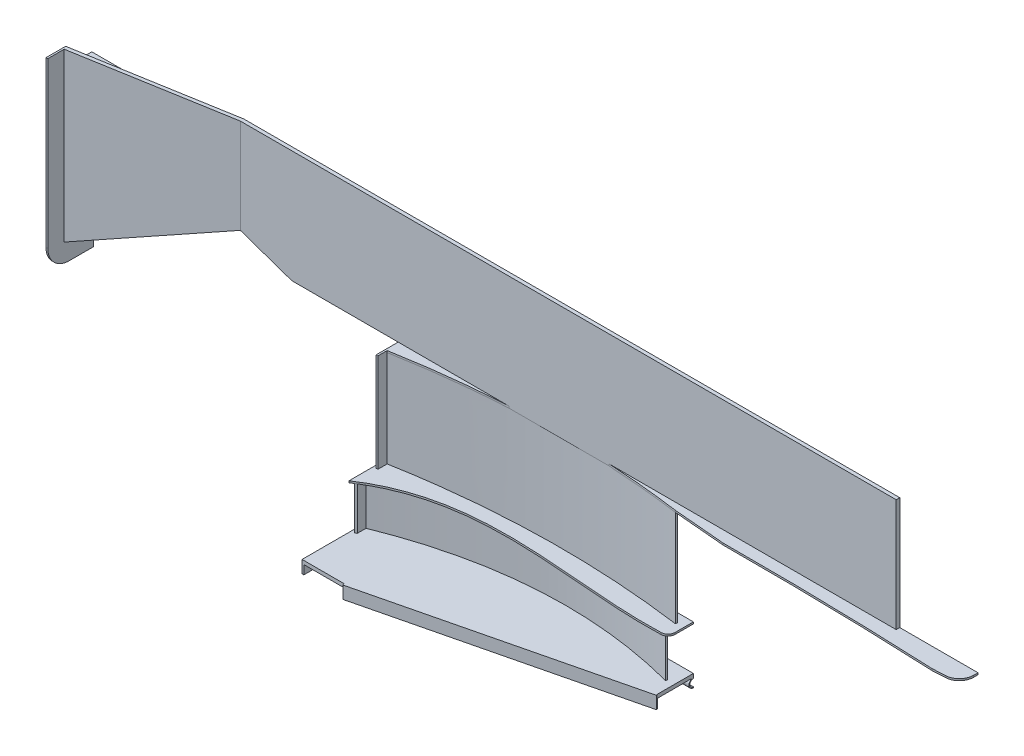
from build123d import *

# Parameters (mm, degrees)
SZKIC1_W                     = 1841.580423823
SZKIC1_H                     = 10
DODANIE_WYCI_GNI_CIE1_DEPTH  = 315
DODANIE_WYCI_GNI_CIE2_DEPTH  = 5
DODANIE_WYCI_GNI_CIE4_DEPTH  = 270
DODANIE_WYCI_GNI_CIE5_DEPTH  = 5
DODANIE_WYCI_GNI_CIE6_DEPTH  = 120
DODANIE_WYCI_GNI_CIE7_DEPTH  = 10
DODANIE_WYCI_GNI_CIE8_DEPTH  = 824.158490967
WYTNIJ_WYCI_GNI_CIE3_DEPTH   = 800
WYTNIJ_WYCI_GNI_CIE4_DEPTH   = 800
WYTNIJ_WYCI_GNI_CIE6_DEPTH   = 800
WYTNIJ_WYCI_GNI_CIE7_DEPTH   = 800
DODANIE_WYCI_GNI_CIE15_REACH = 1830.605
WYTNIJ_WYCI_GNI_CIE8_DEPTH   = 40
SZKIC26_W                    = 726.687402781
SZKIC26_H                    = 35
DODANIE_WYCI_GNI_CIE16_DEPTH = 5
SZKIC10_W                    = 300
SZKIC10_H                    = 35
DODANIE_WYCI_GNI_CIE19_DEPTH = 5
WYTNIJ_WYCI_GNI_CIE10_DEPTH  = 10
WYTNIJ_WYCI_GNI_CIE11_DEPTH  = 35
WYTNIJ_WYCI_GNI_CIE13_DEPTH  = 70
SZKIC30_W                    = 16.697561016
SZKIC30_H                    = 21.994192029
WYTNIJ_WYCI_GNI_CIE14_DEPTH  = 70
DODANIE_WYCI_GNI_CIE20_DEPTH = 5
WYTNIJ_WYCI_GNI_CIE15_DEPTH  = 5
ZAOKR_GLENIE2_R              = 20
SZKIC33_W                    = 30
SZKIC33_H                    = 275
DODANIE_WYCI_GNI_CIE21_DEPTH = 5
SZKIC34_W                    = 36.535261538
SZKIC34_H                    = 120
DODANIE_WYCI_GNI_CIE22_DEPTH = 5
WYTNIJ_WYCI_GNI_CIE16_DEPTH  = 1825.139427117
SZKIC36_W                    = 10
SZKIC36_H                    = 315
DODANIE_WYCI_GNI_CIE23_DEPTH = 90
WYTNIJ_WYCI_GNI_CIE17_DEPTH  = 15
DODANIE_WYCI_GNI_CIE24_DEPTH = 470
WYTNIJ_WYCI_GNI_CIE18_DEPTH  = 235
DODANIE_WYCI_GNI_CIE25_REACH = 2202.156
DODANIE_WYCI_GNI_CIE26_REACH = 2202.156
SZKIC42_W                    = 425.858416348
SZKIC42_H                    = 5
WYTNIJ_WYCI_GNI_CIE20_REACH  = 2202.156
DODANIE_WYCI_GNI_CIE28_DEPTH = 5
SZKIC47_W                    = 59.404380421
SZKIC47_H                    = 10
DODANIE_WYCI_GNI_CIE29_DEPTH = 20
DODANIE_WYCI_GNI_CIE30_DEPTH = 5
WYTNIJ_WYCI_GNI_CIE21_DEPTH  = 5
ZAOKR_GLENIE3_R              = 40
WYTNIJ_WYCI_GNI_CIE22_DEPTH  = 10
WYTNIJ_WYCI_GNI_CIE23_DEPTH  = 120


with BuildPart() as part:
    # Szkic1 → Dodanie-wyciągnięcie1 (new body)
    with BuildSketch(Plane(origin=(0, 0, 0), x_dir=(1, 0, 0), z_dir=(0, 1, 0))):
        with Locations((-708.709788088, -60)):
            Rectangle(SZKIC1_W, SZKIC1_H)
    extrude(amount=-DODANIE_WYCI_GNI_CIE1_DEPTH)

    # Szkic2 → Dodanie-wyciągnięcie2 (add)
    with BuildSketch(Plane.XZ.offset(315)):
        with BuildLine():
            Line((-1189.824091864, 55), (82.698967418, 55))
            Line((82.698967418, 55), (82.698967418, 125))
            add(Edge.make_bspline(
                [(82.698967418, 125), (-575.048967354, 24.979688265), (-1189.824091864, 215)],
                knots=[0, 0, 0, 1, 1, 1], degree=2))
            Line((-1189.824091864, 215), (-1189.824091864, 55))
        make_face()
    extrude(amount=DODANIE_WYCI_GNI_CIE2_DEPTH)

    # Szkic4 → Dodanie-wyciągnięcie4 (add)
    with BuildSketch(Plane.XZ.offset(320)):
        with BuildLine():
            Line((-1182.177359348, 101.771243176), (-1182.177359348, 96.771243176))
            add(Edge.make_bspline(
                [(-385.949338397, 79.815775507), (-787.330452668, 25.09256948), (-1182.177359348, 96.771243176)],
                knots=[0, 0, 0, 1, 1, 1], degree=2))
            Line((-385.949338397, 79.815775507), (-385.949338397, 84.815775507))
            add(Edge.make_bspline(
                [(-385.949338397, 84.815775507), (-787.330452668, 30.09256948), (-1182.177359348, 101.771243176)],
                knots=[0, 0, 0, 1, 1, 1], degree=2))
        make_face()
    extrude(amount=DODANIE_WYCI_GNI_CIE4_DEPTH)

    # Szkic5 → Dodanie-wyciągnięcie5 (add)
    with BuildSketch(Plane.XZ.offset(590)):
        with BuildLine():
            Line((-1189.824091794, 195), (-1189.824091794, 55))
            Line((-1189.824091794, 55), (-365.665600827, 55))
            Line((-365.665600827, 55), (-365.665600827, 125))
            add(Edge.make_bspline(
                [(-1189.824091794, 195), (-948.463478374, 33.501978751), (-627.926523689, 141.485843373), (-365.665600827, 125)],
                knots=[0, 0, 0, 0, 1, 1, 1, 1], degree=3))
        make_face()
    extrude(amount=DODANIE_WYCI_GNI_CIE5_DEPTH)

    # Szkic6 → Dodanie-wyciągnięcie6 (add)
    with BuildSketch(Plane.XZ.offset(595)):
        with BuildLine():
            Line((-1180.731710733, 163.464738462), (-1180.731710733, 158.464738462))
            add(Edge.make_bspline(
                [(-386.71144151, 106.429912395), (-791.410470683, 0.146312653), (-1180.731710733, 158.464738462)],
                knots=[0, 0, 0, 1, 1, 1], degree=2))
            Line((-386.71144151, 106.429912395), (-386.71144151, 111.429912395))
            add(Edge.make_bspline(
                [(-386.71144151, 111.429912395), (-791.410470683, 5.146312653), (-1180.731710733, 163.464738462)],
                knots=[0, 0, 0, 1, 1, 1], degree=2))
        make_face()
    extrude(amount=DODANIE_WYCI_GNI_CIE6_DEPTH)

    # Szkic7 → Dodanie-wyciągnięcie7 (add)
    with BuildSketch(Plane.XZ.offset(715)):
        Polygon((-1189.824091794, 55), (-365.665600827, 55), (-365.665600827, 155), (-1189.824091794, 355), align=None)
    extrude(amount=DODANIE_WYCI_GNI_CIE7_DEPTH)

    # Szkic9 → Dodanie-wyciągnięcie8 (add)
    with BuildSketch(Plane.ZY.offset(1189.824091794)):
        with BuildLine():
            Line((55, -725), (55, -727.5))
            ThreePointArc((55, -727.5), (65, -737.5), (55, -747.5))
            Line((55, -747.5), (55, -750))
            ThreePointArc((55, -750), (67.236328912, -740.053870546), (60, -726.043560763))
            Line((60, -726.043560763), (60, -725))
            Line((60, -725), (55, -725))
        make_face()
    extrude(amount=-DODANIE_WYCI_GNI_CIE8_DEPTH)

    # Szkic14 → Wytnij-wyciągnięcie3 (cut)
    with BuildSketch(Plane(origin=(0, -315, 0), x_dir=(-1, 0, 0), z_dir=(0, -1, 0))):
        Polygon((-212.080423823, -60), (-152.676043402, -65), (-157.068738745, -100.12092383), (-228.037209254, -94.147587352), align=None)
    extrude(amount=-WYTNIJ_WYCI_GNI_CIE3_DEPTH, mode=Mode.SUBTRACT)

    # Szkic15 → Wytnij-wyciągnięcie4 (cut)
    with BuildSketch(Plane.XZ.offset(315)):
        Polygon((-1629.5, 60), (-1533.991072744, 65), (-1548.721576055, 115.377348391), (-1654.554576766, 99.51372944), align=None)
    extrude(amount=-WYTNIJ_WYCI_GNI_CIE4_DEPTH, mode=Mode.SUBTRACT)

    # Szkic17 → Wytnij-wyciągnięcie6 (cut)
    with BuildSketch(Plane.XY):
        Polygon((212.080423823, -300), (152.676043402, -315), (126.143267326, -456.893573372), (421.986335713, -502.224366108), align=None)
    extrude(amount=WYTNIJ_WYCI_GNI_CIE6_DEPTH, mode=Mode.SUBTRACT)

    # Szkic18 → Wytnij-wyciągnięcie7 (cut)
    with BuildSketch(Plane.XY):
        Polygon((-1629.5, -300), (-1533.991072744, -315), (-1533.991072744, -431.408469581), (-1704.18755073, -396.775994669), align=None)
    extrude(amount=WYTNIJ_WYCI_GNI_CIE7_DEPTH, mode=Mode.SUBTRACT)

    # Dodanie-wyciągnięcie15: up to this face of the body (flat: up to its plane)
    dodanie_wyci_gni_cie15_end = Plane(part.part.faces().sort_by_distance((179.077990255, -308.333333333, 58.888888889))[0])
    # Szkic24 → Dodanie-wyciągnięcie15 (add, up to the picked face)
    with BuildSketch(Plane(origin=(0, 0, 0), x_dir=(1, 0, 0), z_dir=(0, 1, 0)), mode=Mode.PRIVATE) as dodanie_wyci_gni_cie15_sk1:
        Polygon((212.080423823, -60), (152.676043402, -65), (212.080423823, -65), align=None)
    dodanie_wyci_gni_cie15_tool1 = split(extrude(dodanie_wyci_gni_cie15_sk1.sketch, amount=-DODANIE_WYCI_GNI_CIE15_REACH, mode=Mode.PRIVATE), bisect_by=dodanie_wyci_gni_cie15_end, keep=Keep.BOTH, mode=Mode.PRIVATE)
    add(dodanie_wyci_gni_cie15_tool1.solids().sort_by(Axis((192.278964, 0, 63.333333), (0, -1, 0)))[0])

    # Szkic25 → Wytnij-wyciągnięcie8 (cut, symmetric)
    with BuildSketch(Plane.XZ.offset(725)):
        Polygon((-1071.856786677, 326.372665231), (-1189.824091794, 326.372665231), (-1281.285885853, 396.255102667), (-1102.826584063, 410.27690495), align=None)
    extrude(amount=WYTNIJ_WYCI_GNI_CIE8_DEPTH, both=True, mode=Mode.SUBTRACT)

    # Szkic26 → Dodanie-wyciągnięcie16 (add)
    with BuildSketch(Plane(origin=(15.185934362, 0, 62.578083739), x_dir=(0.9717950017399135, 0, -0.23582721342822507), z_dir=(0.23582721342822507, 0, 0.9717950017399135))):
        with Locations((-755.248922664, -732.5)):
            Rectangle(SZKIC26_W, SZKIC26_H)
    extrude(amount=DODANIE_WYCI_GNI_CIE16_DEPTH)

    # Szkic10 → Dodanie-wyciągnięcie19 (add)
    with BuildSketch(Plane.ZY.offset(1189.824091794)):
        with Locations((205, -732.5)):
            Rectangle(SZKIC10_W, SZKIC10_H)
    extrude(amount=-DODANIE_WYCI_GNI_CIE19_DEPTH)

    # Szkic27 → Wytnij-wyciągnięcie10 (cut)
    with BuildSketch(Plane(origin=(-1184.824091794, 0, 0), x_dir=(0, 0, -1), z_dir=(1, 0, 0))):
        with BuildLine():
            Line((-55, -747.5), (-38.951461032, -762.248984803))
            Line((-38.951461032, -762.248984803), (-37.343567768, -710.656236911))
            Line((-37.343567768, -710.656236911), (-55, -727.5))
            ThreePointArc((-55, -727.5), (-65, -737.5), (-55, -747.5))
        make_face()
    extrude(amount=-WYTNIJ_WYCI_GNI_CIE10_DEPTH, mode=Mode.SUBTRACT)

    # Szkic28 → Wytnij-wyciągnięcie11 (cut, symmetric)
    with BuildSketch(Plane.XZ.offset(725)):
        Polygon((-1184.824091794, 326.372665231), (-1217.650135451, 326.372665231), (-1219.406429923, 378.737546141), (-1162.034143854, 378.737546141), align=None)
    extrude(amount=WYTNIJ_WYCI_GNI_CIE11_DEPTH, both=True, mode=Mode.SUBTRACT)

    # Szkic29 → Wytnij-wyciągnięcie13 (cut)
    with BuildSketch(Plane.XZ.offset(320)):
        with BuildLine():
            Line((-385.949338397, 84.815775507), (-385.949338397, 334.407178537))
            Line((-385.949338397, 334.407178537), (-1182.177359348, 473.468106308))
            Line((-1182.177359348, 473.468106308), (-1313.585801573, 196.645885604))
            Line((-1313.585801573, 196.645885604), (-1213.513918971, 101.771243176))
            Line((-1213.513918971, 101.771243176), (-1182.177359348, 101.771243176))
            add(Edge.make_bspline(
                [(-871.63878498, 65), (-1027.410026315, 73.675500305), (-1182.177359348, 101.771243176)],
                knots=[0, 0, 0, 1, 1, 1], degree=2))
            Line((-871.63878498, 65), (-592.490024907, 65))
            add(Edge.make_bspline(
                [(-385.949338397, 84.815775507), (-489.436864274, 70.706568575), (-592.490024907, 65)],
                knots=[0, 0, 0, 1, 1, 1], degree=2))
        make_face()
    extrude(amount=-WYTNIJ_WYCI_GNI_CIE13_DEPTH, mode=Mode.SUBTRACT)

    # Szkic30 → Wytnij-wyciągnięcie14 (cut)
    with BuildSketch(Plane.XY.offset(101.771243176)):
        with Locations((-1190.526139856, -325.997096015)):
            Rectangle(SZKIC30_W, SZKIC30_H)
    extrude(amount=-WYTNIJ_WYCI_GNI_CIE14_DEPTH, mode=Mode.SUBTRACT)

    # Szkic31 → Dodanie-wyciągnięcie20 (add)
    with BuildSketch(Plane.XZ.offset(320)):
        Polygon((82.698967418, 125), (-385.949338397, 90.579084574), (-211.590498137, 70.301208148), (82.698967418, 100.951939948), align=None)
    extrude(amount=-DODANIE_WYCI_GNI_CIE20_DEPTH)

    # Szkic32 → Wytnij-wyciągnięcie15 (cut)
    with BuildSketch(Plane(origin=(0, -315, 0), x_dir=(1, 0, 0), z_dir=(0, 1, 0))):
        Polygon((-385.949338397, -84.815775507), (82.698967418, -125), (43.251165214, -321.645953954), (-385.949338397, -284.844179199), align=None)
    extrude(amount=-WYTNIJ_WYCI_GNI_CIE15_DEPTH, mode=Mode.SUBTRACT)

    # Zaokrąglenie2
    zaokr_glenie2_edges = [part.edges().sort_by_distance(p)[0] for p in [
        (-365.665600827, -592.5, 125),
    ]]
    fillet(zaokr_glenie2_edges, radius=ZAOKR_GLENIE2_R)

    # Szkic33 → Dodanie-wyciągnięcie21 (add)
    with BuildSketch(Plane.ZY.offset(1182.177359348)):
        with Locations((111.771243176, -452.5)):
            Rectangle(SZKIC33_W, SZKIC33_H)
    extrude(amount=-DODANIE_WYCI_GNI_CIE21_DEPTH)

    # Szkic34 → Dodanie-wyciągnięcie22 (add)
    with BuildSketch(Plane.ZY.offset(1180.731710733)):
        with Locations((176.732369231, -655)):
            Rectangle(SZKIC34_W, SZKIC34_H)
    extrude(amount=-DODANIE_WYCI_GNI_CIE22_DEPTH)

    # Szkic35 → Wytnij-wyciągnięcie16 (cut, through all)
    with BuildSketch(Plane(origin=(0, 0, 0), x_dir=(1, 0, 0), z_dir=(0, 1, 0))):
        Polygon((-1533.991072744, -65), (-1533.991072744, -13.036157564), (-1638.767665128, -13.036157564), (-1638.767665128, -80.773392513), (-1533.991072744, -80.773392513), align=None)
    extrude(amount=-WYTNIJ_WYCI_GNI_CIE16_DEPTH, mode=Mode.SUBTRACT)

    # Szkic36 → Dodanie-wyciągnięcie23 (add)
    with BuildSketch(Plane.ZY.offset(1533.991072744)):
        with Locations((60, -157.5)):
            Rectangle(SZKIC36_W, SZKIC36_H)
    extrude(amount=DODANIE_WYCI_GNI_CIE23_DEPTH)

    # Szkic37 → Wytnij-wyciągnięcie17 (cut)
    with BuildSketch(Plane.XY.offset(65)):
        Polygon((-1623.991072744, -265), (-1480, -315), (-1582.155270027, -427.098221847), (-1743.661021139, -471.749811861), (-1686.658991335, -216.190711572), align=None)
    extrude(amount=-WYTNIJ_WYCI_GNI_CIE17_DEPTH, mode=Mode.SUBTRACT)

    # Szkic38 → Dodanie-wyciągnięcie24 (add)
    with BuildSketch(Plane(origin=(0, 0, 0), x_dir=(1, 0, 0), z_dir=(0, 1, 0))):
        Polygon((-1623.991072744, -65), (-1623.991072744, -55), (-2049.849489092, -128.23732135), (-2049.849489092, -138.23732135), align=None)
    extrude(amount=-DODANIE_WYCI_GNI_CIE24_DEPTH)

    # Szkic39 → Wytnij-wyciągnięcie18 (cut, symmetric)
    with BuildSketch(Plane.XY.offset(65)):
        Polygon((-1623.991072744, -265), (-2049.849489092, -470), (-2049.849489092, -632.364405532), (-1604.615661805, -507.9476393), align=None)
    extrude(amount=WYTNIJ_WYCI_GNI_CIE18_DEPTH, both=True, mode=Mode.SUBTRACT)

    # Dodanie-wyciągnięcie25: up to this face of the body (flat: up to its plane)
    dodanie_wyci_gni_cie25_end = Plane(part.part.faces().sort_by_distance((-1856.716420453, -188.514739229, 95.023116656))[0])
    # Szkic40 → Dodanie-wyciągnięcie25 (add, up to the picked face)
    with BuildSketch(Plane(origin=(0, 0, 55), x_dir=(-1, 0, 0), z_dir=(0, 0, -1)), mode=Mode.PRIVATE) as dodanie_wyci_gni_cie25_sk1:
        Polygon((1623.991072744, -265), (2049.849489092, -470), (2049.849489092, -465), (1623.991072744, -260), align=None)
    dodanie_wyci_gni_cie25_tool1 = split(extrude(dodanie_wyci_gni_cie25_sk1.sketch, amount=-DODANIE_WYCI_GNI_CIE25_REACH, mode=Mode.PRIVATE), bisect_by=dodanie_wyci_gni_cie25_end, keep=Keep.BOTH, mode=Mode.PRIVATE)
    add(dodanie_wyci_gni_cie25_tool1.solids().sort_by(Axis((-1836.920281, -365, 55), (0, 0, 1)))[0])

    # Dodanie-wyciągnięcie26: up to this face of the body (flat: up to its plane)
    dodanie_wyci_gni_cie26_end = Plane(part.part.faces().sort_by_distance((-1856.989470654, -186.08045977, 95.07007467))[0])
    # Szkic42 → Dodanie-wyciągnięcie26 (add, up to the picked face)
    with BuildSketch(Plane(origin=(0, 0, 55), x_dir=(-1, 0, 0), z_dir=(0, 0, -1)), mode=Mode.PRIVATE) as dodanie_wyci_gni_cie26_sk1:
        with BuildLine():
            Line((1623.991072744, -244.355149627), (1623.991072744, -239.355149627))
            add(Edge.make_bspline(
                [(2049.849489092, -401.340406152), (1855.427484027, -273.909465931), (1623.991072744, -239.355149627)],
                knots=[0, 0, 0, 1, 1, 1], degree=2))
            Line((2049.849489092, -401.340406152), (2049.849489092, -406.340406152))
            add(Edge.make_bspline(
                [(1623.991072744, -244.355149627), (1855.427484027, -278.909465931), (2049.849489092, -406.340406152)],
                knots=[0, 0, 0, 1, 1, 1], degree=2))
        make_face()
    dodanie_wyci_gni_cie26_tool1 = split(extrude(dodanie_wyci_gni_cie26_sk1.sketch, amount=-DODANIE_WYCI_GNI_CIE26_REACH, mode=Mode.PRIVATE), bisect_by=dodanie_wyci_gni_cie26_end, keep=Keep.BOTH, mode=Mode.PRIVATE)
    # Szkic42 → Dodanie-wyciągnięcie26 (add, up to the picked face)
    with BuildSketch(Plane(origin=(0, 0, 55), x_dir=(-1, 0, 0), z_dir=(0, 0, -1)), mode=Mode.PRIVATE) as dodanie_wyci_gni_cie26_sk2:
        with BuildLine():
            Line((1623.991072744, -200), (1623.991072744, -205))
            add(Edge.make_bspline(
                [(1623.991072744, -205), (1843.10350801, -226.100859593), (2049.849489092, -299.983230738)],
                knots=[0, 0, 0, 1, 1, 1], degree=2))
            Line((2049.849489092, -299.983230738), (2049.849489092, -294.983230738))
            add(Edge.make_bspline(
                [(1623.991072744, -200), (1843.10350801, -221.100859593), (2049.849489092, -294.983230738)],
                knots=[0, 0, 0, 1, 1, 1], degree=2))
        make_face()
    dodanie_wyci_gni_cie26_tool2 = split(extrude(dodanie_wyci_gni_cie26_sk2.sketch, amount=-DODANIE_WYCI_GNI_CIE26_REACH, mode=Mode.PRIVATE), bisect_by=dodanie_wyci_gni_cie26_end, keep=Keep.BOTH, mode=Mode.PRIVATE)
    # Szkic42 → Dodanie-wyciągnięcie26 (add, up to the picked face)
    with BuildSketch(Plane(origin=(0, 0, 55), x_dir=(-1, 0, 0), z_dir=(0, 0, -1)), mode=Mode.PRIVATE) as dodanie_wyci_gni_cie26_sk3:
        with Locations((1836.920280918, -52.5)):
            Rectangle(SZKIC42_W, SZKIC42_H)
    dodanie_wyci_gni_cie26_tool3 = split(extrude(dodanie_wyci_gni_cie26_sk3.sketch, amount=-DODANIE_WYCI_GNI_CIE26_REACH, mode=Mode.PRIVATE), bisect_by=dodanie_wyci_gni_cie26_end, keep=Keep.BOTH, mode=Mode.PRIVATE)
    # Szkic42 → Dodanie-wyciągnięcie26 (add, up to the picked face)
    with BuildSketch(Plane(origin=(0, 0, 55), x_dir=(-1, 0, 0), z_dir=(0, 0, -1)), mode=Mode.PRIVATE) as dodanie_wyci_gni_cie26_sk4:
        with Locations((1836.920280918, -147.5)):
            Rectangle(SZKIC42_W, SZKIC42_H)
    dodanie_wyci_gni_cie26_tool4 = split(extrude(dodanie_wyci_gni_cie26_sk4.sketch, amount=-DODANIE_WYCI_GNI_CIE26_REACH, mode=Mode.PRIVATE), bisect_by=dodanie_wyci_gni_cie26_end, keep=Keep.BOTH, mode=Mode.PRIVATE)
    add(dodanie_wyci_gni_cie26_tool1.solids().sort_by(Axis((-1628.565343, -241.85515, 55), (0, 0, 1)))[0])
    add(dodanie_wyci_gni_cie26_tool2.solids().sort_by(Axis((-1628.365453, -202.5, 55), (0, 0, 1)))[0])
    add(dodanie_wyci_gni_cie26_tool3.solids().sort_by(Axis((-1836.920281, -52.5, 55), (0, 0, 1)))[0])
    add(dodanie_wyci_gni_cie26_tool4.solids().sort_by(Axis((-1836.920281, -147.5, 55), (0, 0, 1)))[0])

    # Wytnij-wyciągnięcie20: up to this face of the body (flat: up to its plane)
    wytnij_wyci_gni_cie20_end = Plane(part.part.faces().sort_by_distance((-1876.106863036, -284.989952008, 98.357802599))[0])
    # Szkic44 → Wytnij-wyciągnięcie20 (cut, up to the picked face)
    with BuildSketch(Plane(origin=(0, 0, 55), x_dir=(-1, 0, 0), z_dir=(0, 0, -1)), mode=Mode.PRIVATE) as wytnij_wyci_gni_cie20_sk1:
        with BuildLine():
            Line((2049.849489092, -406.340406152), (2049.849489092, -401.340406152))
            add(Edge.make_bspline(
                [(1623.991072744, -239.355149627), (1855.427484027, -273.909465931), (2049.849489092, -401.340406152)],
                knots=[0, 0, 0, 1, 1, 1], degree=2))
            Line((1623.991072744, -239.355149627), (1623.991072744, -244.355149627))
            add(Edge.make_bspline(
                [(2049.849489092, -406.340406152), (1855.427484027, -278.909465931), (1623.991072744, -244.355149627)],
                knots=[0, 0, 0, 1, 1, 1], degree=2))
        make_face()
    wytnij_wyci_gni_cie20_tool1 = split(extrude(wytnij_wyci_gni_cie20_sk1.sketch, amount=-WYTNIJ_WYCI_GNI_CIE20_REACH, mode=Mode.PRIVATE), bisect_by=wytnij_wyci_gni_cie20_end, keep=Keep.BOTH, mode=Mode.PRIVATE)
    add(wytnij_wyci_gni_cie20_tool1.solids().sort_by(Axis((-2049.392062, -403.840406, 55), (0, 0, 1)))[0], mode=Mode.SUBTRACT)

    # Szkic45 → Dodanie-wyciągnięcie28 (add)
    with BuildSketch(Plane.ZY.offset(2049.849489092)):
        with BuildLine():
            Line((128.23732135, 0), (183.23732135, 0))
            Line((183.23732135, 0), (183.23732135, -460))
            ThreePointArc((183.23732135, -460), (165.663728222, -502.426406871), (123.23732135, -520))
            Line((123.23732135, -520), (55, -520))
            Line((55, -520), (55, -465))
            Line((55, -465), (128.23732135, -465))
            Line((128.23732135, -465), (128.23732135, 0))
        make_face()
    extrude(amount=-DODANIE_WYCI_GNI_CIE28_DEPTH)

    # Szkic47 → Dodanie-wyciągnięcie29 (add)
    with BuildSketch(Plane.XZ.offset(315)):
        with Locations((182.378233613, 60)):
            Rectangle(SZKIC47_W, SZKIC47_H)
    extrude(amount=-DODANIE_WYCI_GNI_CIE29_DEPTH)

    # Szkic48 → Dodanie-wyciągnięcie30 (add)
    with BuildSketch(Plane.XZ.offset(315)):
        Polygon((82.698967418, 125), (431.080423823, 105), (431.080423823, 55), (212.080423823, 55), (82.698967418, 55), align=None)
    extrude(amount=DODANIE_WYCI_GNI_CIE30_DEPTH)

    # Szkic49 → Wytnij-wyciągnięcie21 (cut)
    with BuildSketch(Plane.XZ.offset(320)):
        with BuildLine():
            Line((-29.805838274, 115.353281315), (-93.441590749, 240.975899277))
            Line((-93.441590749, 240.975899277), (363.646365475, 245.253460365))
            Line((363.646365475, 245.253460365), (300.768997598, 112.480962251))
            add(Edge.make_bspline(
                [(-29.805838274, 115.353281315), (135.498032571, 122.219856749), (300.768997598, 112.480962251)],
                knots=[0, 0, 0, 1, 1, 1], degree=2))
        make_face()
    extrude(amount=-WYTNIJ_WYCI_GNI_CIE21_DEPTH, mode=Mode.SUBTRACT)

    # Zaokrąglenie3
    zaokr_glenie3_edges = [part.edges().sort_by_distance(p)[0] for p in [
        (431.080423823, -317.5, 105),
    ]]
    fillet(zaokr_glenie3_edges, radius=ZAOKR_GLENIE3_R)

    # Szkic50 → Wytnij-wyciągnięcie22 (cut)
    with BuildSketch(Plane.XZ.offset(320)):
        with BuildLine():
            Line((-240.172445172, 97.315407599), (-253.233513174, 230.819913371))
            Line((-253.233513174, 230.819913371), (380.265543059, 230.819913371))
            Line((380.265543059, 230.819913371), (357.205892856, 109.241013958))
            add(Edge.make_bspline(
                [(-240.172445172, 97.315407599), (58.727979329, 95.460968942), (357.205892856, 109.241013958)],
                knots=[0, 0, 0, 1, 1, 1], degree=2))
        make_face()
    extrude(amount=-WYTNIJ_WYCI_GNI_CIE22_DEPTH, mode=Mode.SUBTRACT)

    # Szkic53 → Wytnij-wyciągnięcie23 (cut)
    with BuildSketch(Plane(origin=(0, -595, 0), x_dir=(1, 0, 0), z_dir=(0, 1, 0))):
        with BuildLine():
            Line((-1180.731710733, -189.066503083), (-1180.731710733, -195))
            Line((-1180.731710733, -195), (-1175.731710733, -195))
            Line((-1175.731710733, -195), (-1175.731710733, -185.928934683))
            ThreePointArc((-1175.731710733, -185.928934683), (-1178.236624803, -187.489887866), (-1180.731710733, -189.066503083))
        make_face()
    extrude(amount=-WYTNIJ_WYCI_GNI_CIE23_DEPTH, mode=Mode.SUBTRACT)


solid = part.part
